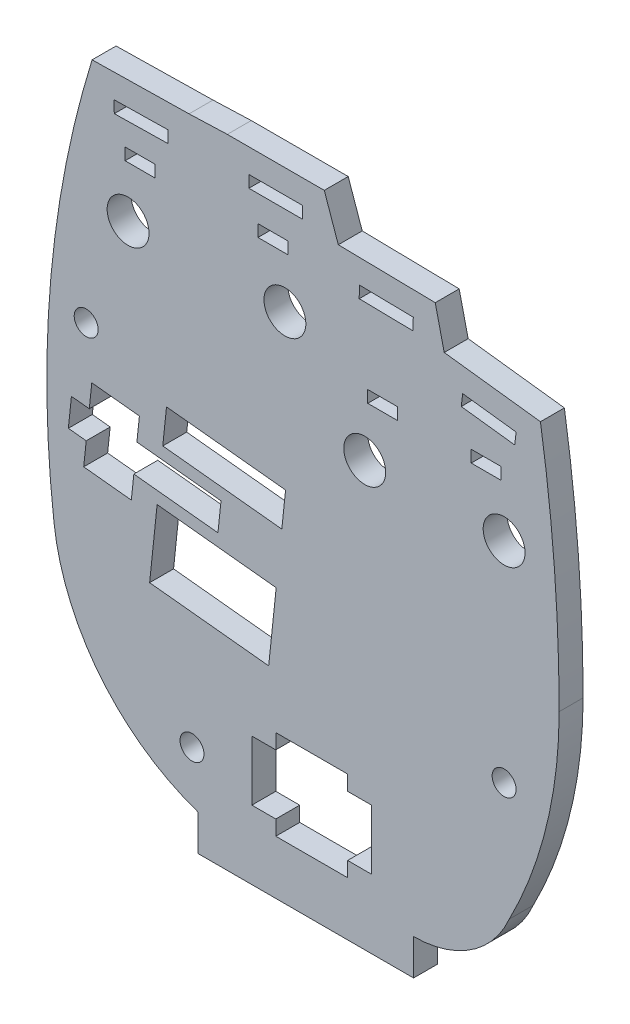
from build123d import *

# Parameters (mm, degrees)
SKETCH1_R           = 2
SKETCH1_R_2         = 3.5
SKETCH1_W           = 9.000072
SKETCH1_H           = 2
SKETCH1_W_2         = 5
BOSS_EXTRUDE1_DEPTH = 4


with BuildPart() as part:
    # Sketch1 → Boss-Extrude1 (new body)
    with BuildSketch(Plane.XY):
        with BuildLine():
            Line((-12.978640908, -18), (-12.978640908, -24))
            Line((-12.978640908, -24), (23.021359092, -24))
            Line((23.021359092, -24), (23.021359092, -18))
            ThreePointArc((23.021359092, -18), (32.58126188, -15.140073441), (39, -7.5))
            ThreePointArc((39, -7.5), (45.227131985, 9.097629123), (47.343034567, 26.698237678))
            ThreePointArc((47.343034567, 26.698237678), (46.561018226, 46.955835458), (44.219623828, 67.092858318))
            Line((44.219623828, 67.092858318), (28.140376172, 69.067141682))
            Line((28.140376172, 69.067141682), (26.638766331, 75.523635508))
            Line((26.638766331, 75.523635508), (10.441233669, 75.806364492))
            Line((10.441233669, 75.806364492), (8.1, 82.51))
            Line((8.1, 82.51), (-8.1, 82.51))
            Line((-8.1, 82.51), (-14.491217975, 82.280462515))
            Line((-14.491217975, 82.280462515), (-30.688782025, 81.999537485))
            ThreePointArc((-30.688782025, 81.999537485), (-37.567707395, 47.245827753), (-37.052658257, 11.821617405))
            ThreePointArc((-37.052658257, 11.821617405), (-29.300451665, -6.548172019), (-12.978640908, -18))
        make_face()
        with Locations((38.147341743, 11.821617405)):
            Circle(SKETCH1_R, mode=Mode.SUBTRACT)
        with Locations((-24.678960076, 61.651218734)):
            Circle(SKETCH1_R_2, mode=Mode.SUBTRACT)
        with Locations((1.521420673, 61.651218734)):
            Circle(SKETCH1_R_2, mode=Mode.SUBTRACT)
        with Locations((14.86306514, 46.821617405)):
            Circle(SKETCH1_R_2, mode=Mode.SUBTRACT)
        with Locations((38.147341743, 46.821617405)):
            Circle(SKETCH1_R_2, mode=Mode.SUBTRACT)
        with Locations((-31.681501662, 43.456405989)):
            Circle(SKETCH1_R, mode=Mode.SUBTRACT)
        with Locations((-14, -9.124358763)):
            Circle(SKETCH1_R, mode=Mode.SUBTRACT)
        with Locations((0, 77.51)):
            Rectangle(SKETCH1_W, SKETCH1_H, mode=Mode.SUBTRACT)
        Polygon((-4, -2.5), (0, -2.5), (0, 0), (12, 0), (12, -2.5), (16, -2.5), (16, -12.5), (12, -12.5), (12, -15), (0, -15), (0, -12.5), (-4, -12.5), align=None, mode=Mode.SUBTRACT)
        with Locations((35.147341743, 56.321617405)):
            Rectangle(SKETCH1_W_2, SKETCH1_H, mode=Mode.SUBTRACT)
        Polygon((-27.019995137, 78.062566115), (-18.021276454, 78.218636824), (-17.986594351, 76.218937559), (-26.985313034, 76.062866849), align=None, mode=Mode.SUBTRACT)
        with Locations((17.86306514, 56.321617405)):
            Rectangle(SKETCH1_W_2, SKETCH1_H, mode=Mode.SUBTRACT)
        with Locations((-0.478579327, 71.151218734)):
            Rectangle(SKETCH1_W_2, SKETCH1_H, mode=Mode.SUBTRACT)
        Polygon((13.970839752, 71.744145677), (13.935934939, 69.744450286), (22.934636184, 69.587377372), (22.969540997, 71.587072762), align=None, mode=Mode.SUBTRACT)
        Polygon((40.15901604, 63.561398961), (31.226029212, 64.658231826), (30.982290526, 62.673139523), (39.915277354, 61.576306658), align=None, mode=Mode.SUBTRACT)
        Polygon((1.632632483, 35.912105076), (1.005748572, 29.944943559), (-18.884789816, 32.034556594), (-18.257905905, 38.00171811), align=None, mode=Mode.SUBTRACT)
        with Locations((-22.678960076, 71.151218734)):
            Rectangle(SKETCH1_W_2, SKETCH1_H, mode=Mode.SUBTRACT)
        Polygon((0.065422707, 20.994201285), (-1.188345114, 9.059878252), (-21.078883502, 11.149491286), (-19.825115681, 23.083814319), align=None, mode=Mode.SUBTRACT)
        Polygon((-9.666, 24.072796069), (-9.153, 28.955923243), (-23.205665371, 30.432234852), (-22.787742764, 34.410342529), (-30.743958119, 35.246187743), (-31.161880726, 31.268080066), (-34.143965433, 31.581364852), (-34.656965433, 26.698237678), (-31.674880726, 26.384952891), (-32.092803333, 22.406845214), (-24.136587978, 21.571), (-23.718665371, 25.549107678), align=None, mode=Mode.SUBTRACT)
    extrude(amount=BOSS_EXTRUDE1_DEPTH)


solid = part.part
